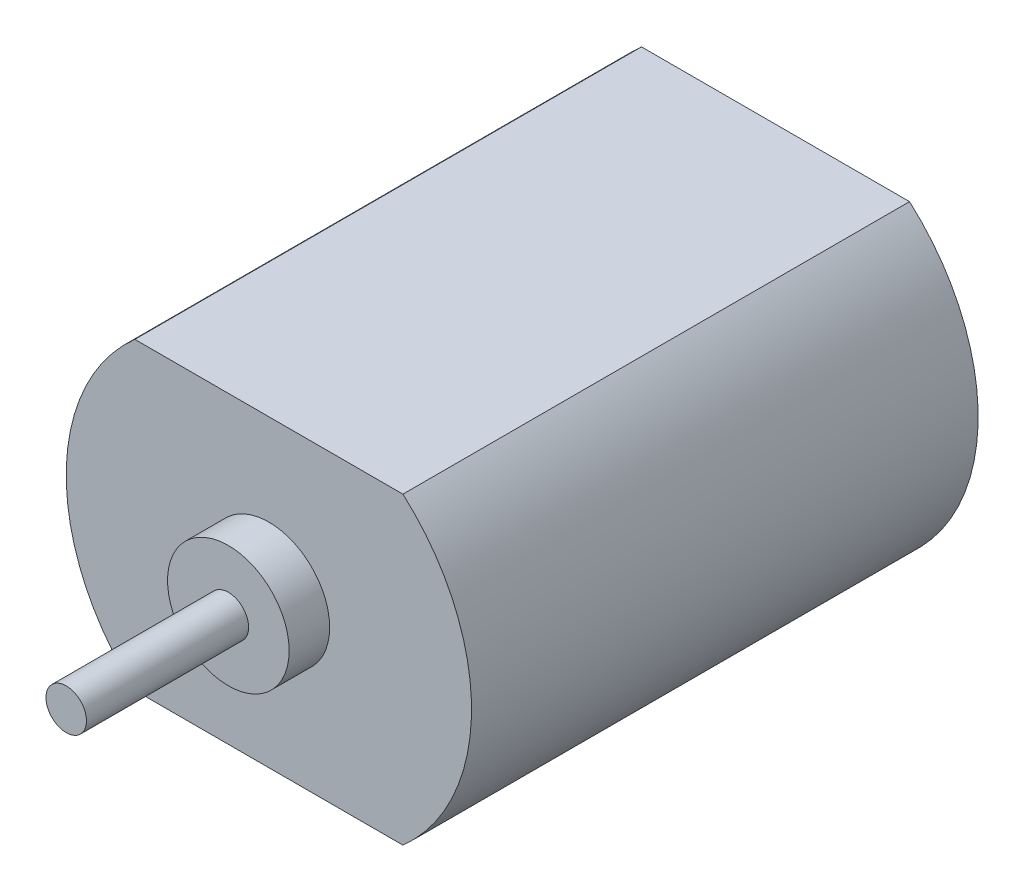
from build123d import *

# Parameters (mm, degrees)
BOSS_EXTRU_1_DEPTH = 25
ESQUISSE2_R        = 3
BOSS_EXTRU_2_DEPTH = 2
ESQUISSE3_R        = 1
BOSS_EXTRU_3_DEPTH = 8


with BuildPart() as part:
    # Esquisse1 → Boss.-Extru.1 (new body)
    with BuildSketch(Plane.XY):
        with BuildLine():
            Line((-6.614378278, 7.5), (6.614378278, 7.5))
            ThreePointArc((6.614378278, 7.5), (10, 0), (6.614378278, -7.5))
            Line((6.614378278, -7.5), (-6.614378278, -7.5))
            ThreePointArc((-6.614378278, -7.5), (-10, 0), (-6.614378278, 7.5))
        make_face()
    extrude(amount=BOSS_EXTRU_1_DEPTH)

    # Esquisse2 → Boss.-Extru.2 (add)
    with BuildSketch(Plane.XY.offset(25)):
        Circle(ESQUISSE2_R)
    extrude(amount=BOSS_EXTRU_2_DEPTH)

    # Esquisse3 → Boss.-Extru.3 (add)
    with BuildSketch(Plane.XY.offset(27)):
        Circle(ESQUISSE3_R)
    extrude(amount=BOSS_EXTRU_3_DEPTH)


solid = part.part
